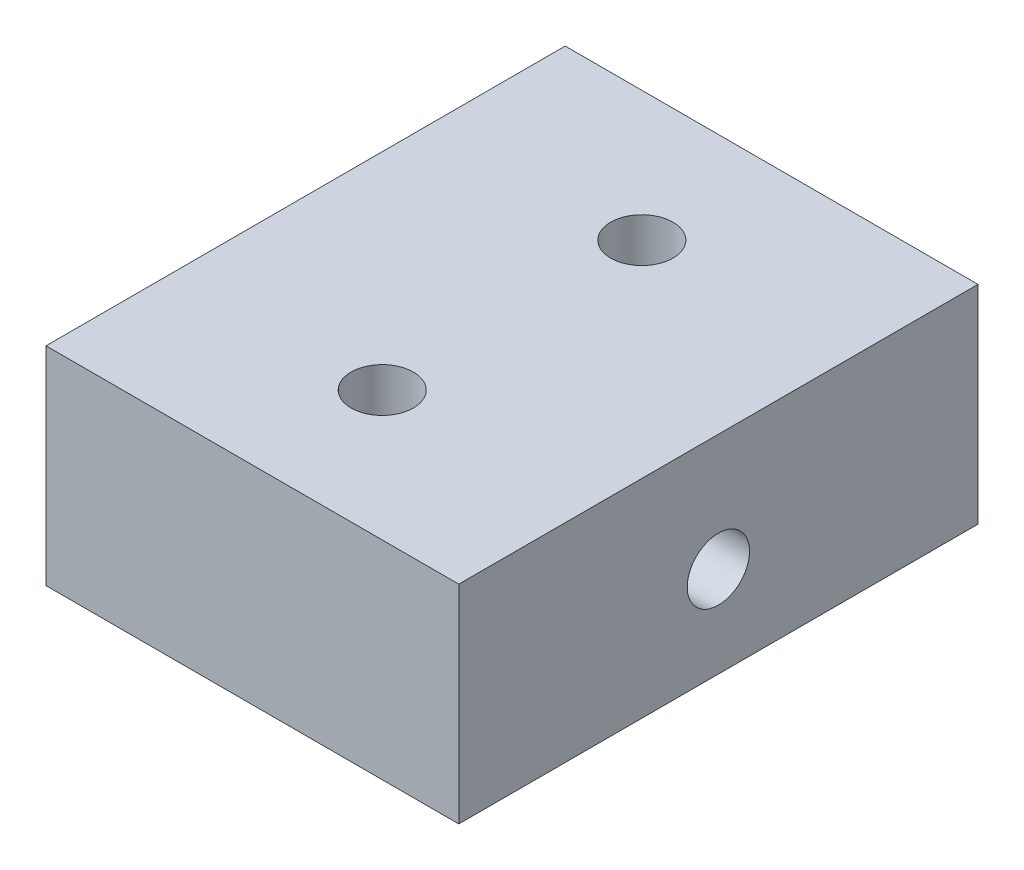
from build123d import *

# Parameters (mm, degrees)
SKETCH1_W           = 15.9
SKETCH1_H           = 8
BOSS_EXTRUDE1_DEPTH = 20
SKETCH2_R           = 1.2
CUT_EXTRUDE1_DEPTH  = 16.9
SKETCH3_R           = 1.2
CUT_EXTRUDE2_DEPTH  = 9


with BuildPart() as part:
    # Sketch1 → Boss-Extrude1 (new body)
    with BuildSketch(Plane.XY):
        with Locations((7.95, 4)):
            Rectangle(SKETCH1_W, SKETCH1_H)
    extrude(amount=BOSS_EXTRUDE1_DEPTH)

    # Sketch2 → Cut-Extrude1 (cut, through all)
    with BuildSketch(Plane(origin=(15.9, 0, 0), x_dir=(0, 0, -1), z_dir=(1, 0, 0))):
        with Locations((-10, 3.5)):
            Circle(SKETCH2_R)
    extrude(amount=-CUT_EXTRUDE1_DEPTH, mode=Mode.SUBTRACT)

    # Sketch3 → Cut-Extrude2 (cut, through all)
    with BuildSketch(Plane(origin=(0, 8, 0), x_dir=(1, 0, 0), z_dir=(0, 1, 0))):
        with Locations((7.95, -15)):
            Circle(SKETCH3_R)
        with Locations((7.95, -5)):
            Circle(SKETCH3_R)
    extrude(amount=-CUT_EXTRUDE2_DEPTH, mode=Mode.SUBTRACT)


solid = part.part
